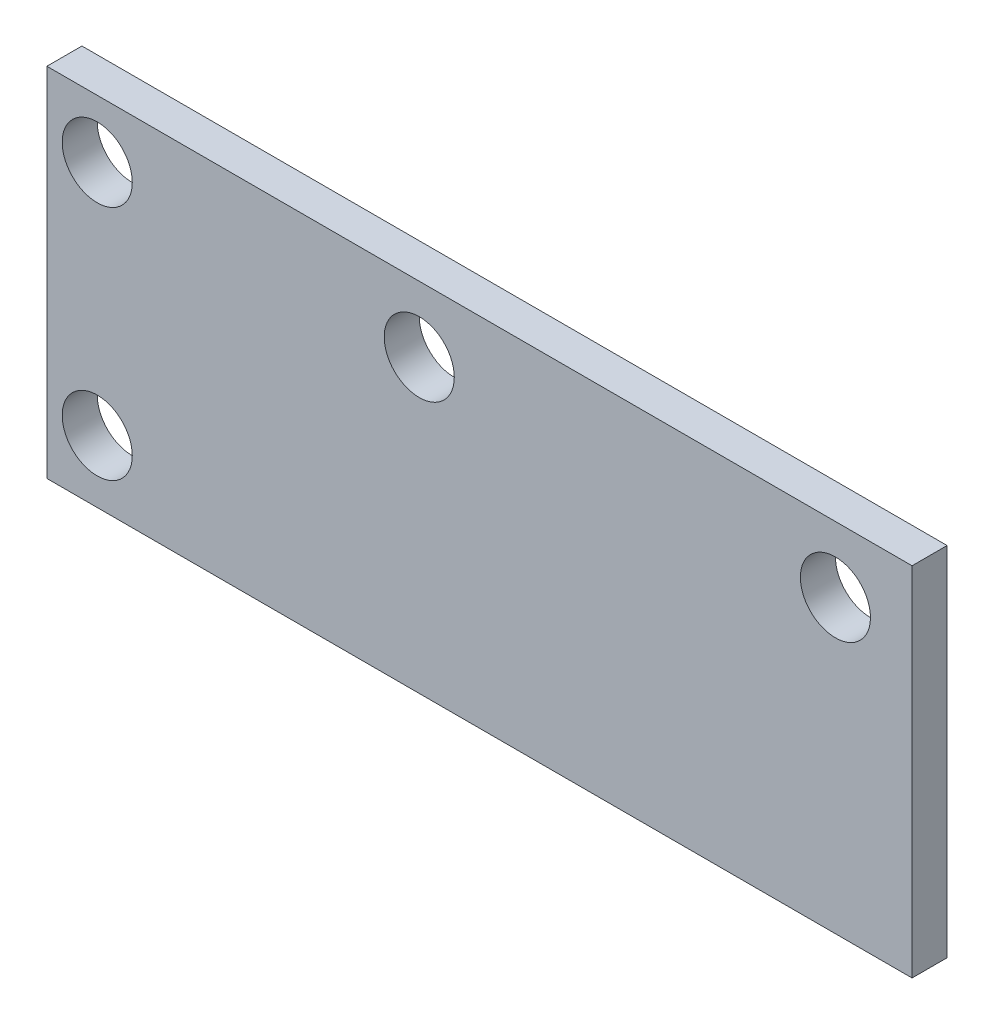
from build123d import *

# Parameters (mm, degrees)
SCHIZZO1_W                   = 39.5
SCHIZZO1_H                   = 16.3
ESTRUSIONE_ESTRUSIONE1_DEPTH = 1.6
SCHIZZO2_R                   = 1.6
TAGLIO_ESTRUSIONE1_DEPTH     = 2.6


with BuildPart() as part:
    # Schizzo1 → Estrusione-Estrusione1 (new body)
    with BuildSketch(Plane.XY):
        Rectangle(SCHIZZO1_W, SCHIZZO1_H)
    extrude(amount=ESTRUSIONE_ESTRUSIONE1_DEPTH)

    # Schizzo2 → Taglio-Estrusione1 (cut, through all)
    with BuildSketch(Plane.XY.offset(1.6)):
        with Locations((-2.75, 5.15)):
            Circle(SCHIZZO2_R)
        with Locations((16.25, 5.15)):
            Circle(SCHIZZO2_R)
        with Locations((-17.451461021, 5.5)):
            Circle(SCHIZZO2_R)
        with Locations((-17.451461021, -5.3)):
            Circle(SCHIZZO2_R)
    extrude(amount=-TAGLIO_ESTRUSIONE1_DEPTH, mode=Mode.SUBTRACT)


solid = part.part
